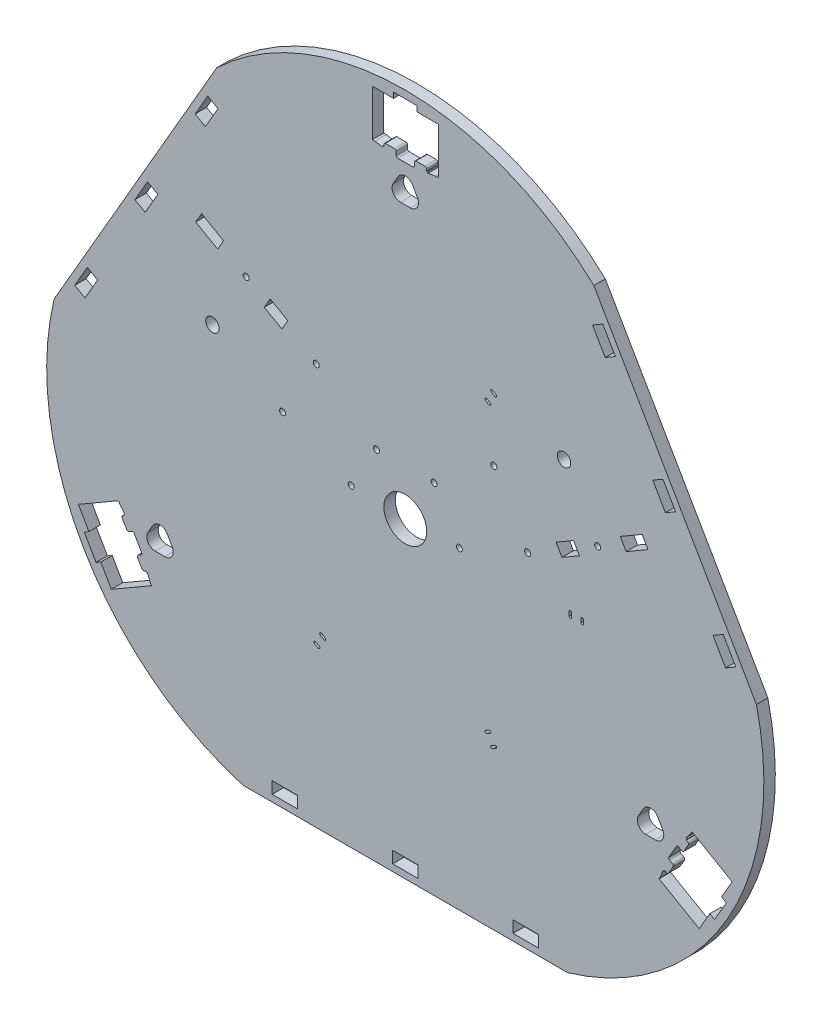
from build123d import *

# Parameters (mm, degrees)
SKETCH1_R                = 12.7
BOSS_EXTRUDE1_DEPTH      = 6.8
SKETCH2_W                = 15
SKETCH2_H                = 7
CUT_EXTRUDE1_DEPTH       = 6.8
CUT_EXTRUDE2_DEPTH       = 6.8
CUT_EXTRUDE3_DEPTH       = 6.8
FILLET1_R                = 1
CIRPATTERN1_COUNT        = 3
CIRPATTERN1_COPY_1_DEPTH = 6.8
CIRPATTERN1_COPY_2_DEPTH = 6.8
FILLET1_OF_CIRPATTERN1_R = 1
SKETCH5_R                = 1.775
SKETCH5_R_2              = 4
CUT_EXTRUDE4_DEPTH       = 6.8
CIRPATTERN2_COUNT        = 3
CUT_EXTRUDE5_DEPTH       = 6.8
CIRPATTERN3_COUNT        = 4
CIRPATTERN3_ANGLE        = 180


with BuildPart() as part:
    # Sketch1 → Boss-Extrude1 (new body)
    with BuildSketch(Plane.XY):
        with BuildLine():
            Line((-96.50625, -185), (96.50625, -185))
            ThreePointArc((96.50625, -185), (191.056759621, -110.306671598), (208.4678247, 8.923135876))
            Line((208.4678247, 8.923135876), (111.9615747, 176.076864124))
            ThreePointArc((111.9615747, 176.076864124), (0, 220.613343196), (-111.9615747, 176.076864124))
            Line((-111.9615747, 176.076864124), (-208.4678247, 8.923135876))
            ThreePointArc((-208.4678247, 8.923135876), (-191.056759621, -110.306671598), (-96.50625, -185))
        make_face()
        Circle(SKETCH1_R, mode=Mode.SUBTRACT)
    extrude(amount=BOSS_EXTRUDE1_DEPTH)

    # Sketch2 → Cut-Extrude1 (cut)
    with BuildSketch(Plane.XY.offset(6.8)):
        with Locations((-71.5, -177.5)):
            Rectangle(SKETCH2_W, SKETCH2_H)
        with Locations((0, -177.5)):
            Rectangle(SKETCH2_W, SKETCH2_H)
        with Locations((71.5, -177.5)):
            Rectangle(SKETCH2_W, SKETCH2_H)
    cut_extrude1 = extrude(amount=-CUT_EXTRUDE1_DEPTH, mode=Mode.SUBTRACT)

    # Sketch3 → Cut-Extrude2 (cut)
    with BuildSketch(Plane.XY.offset(6.8)):
        Polygon((0, 216.05), (7, 216.05), (7, 212.8), (19.58, 212.8), (19.58, 185.3), (18.08, 185.3), (13.535999488, 184.600010636), (13.270052338, 185.3), (12.7, 185.3), (12.7, 187.3), (5.45, 187.3), (5.45, 183.3), (0, 183.3), align=None)
    cut_extrude2 = extrude(amount=-CUT_EXTRUDE2_DEPTH, mode=Mode.SUBTRACT)

    # Mirror1: Cut-Extrude2 across plane
    add(cut_extrude2.mirror(Plane(origin=(0, 0, 0), x_dir=(0, 0, 1), z_dir=(1, 0, 0))), mode=Mode.SUBTRACT)

    # Sketch4 → Cut-Extrude3 (cut)
    with BuildSketch(Plane.XY.offset(6.8)):
        with BuildLine():
            Line((-2.9, 161.527052658), (2.9, 161.527052658))
            ThreePointArc((2.9, 161.527052658), (7.186825749, 164.002052658), (7.186825749, 168.952052658))
            Line((7.186825749, 168.952052658), (4.286825749, 173.975))
            ThreePointArc((4.286825749, 173.975), (0, 176.45), (-4.286825749, 173.975))
            Line((-4.286825749, 173.975), (-7.186825749, 168.952052658))
            ThreePointArc((-7.186825749, 168.952052658), (-7.186825749, 164.002052658), (-2.9, 161.527052658))
        make_face()
    cut_extrude3 = extrude(amount=-CUT_EXTRUDE3_DEPTH, mode=Mode.SUBTRACT)

    # Fillet1
    fillet1_edges = [part.edges().sort_by_distance(p)[0] for p in [
        (-5.45, 183.3, 3.4),
        (-5.45, 187.3, 3.4),
        (-12.7, 187.3, 3.4),
        (12.7, 187.3, 3.4),
        (5.45, 187.3, 3.4),
        (5.45, 183.3, 3.4),
    ]]
    fillet(fillet1_edges, radius=FILLET1_R)

    # CirPattern1: Cut-Extrude2, Cut-Extrude3, Cut-Extrude1 ×3 about axis
    cirpattern1_axis = Axis((0, 0, 0), (0, 0, 1))
    for i in range(1, CIRPATTERN1_COUNT):
        add(cut_extrude2.rotate(cirpattern1_axis, i * 360 / CIRPATTERN1_COUNT), mode=Mode.SUBTRACT)
        add(cut_extrude3.rotate(cirpattern1_axis, i * 360 / CIRPATTERN1_COUNT), mode=Mode.SUBTRACT)
        add(cut_extrude1.rotate(cirpattern1_axis, i * 360 / CIRPATTERN1_COUNT), mode=Mode.SUBTRACT)

    # CirPattern1 copy 1 sketch → CirPattern1 copy 1 (cut)
    with BuildSketch(Plane(origin=(0, 0, 6.8), x_dir=(0.5, -0.866025404, 0), z_dir=(0, 0, 1))):
        Polygon((0, -216.05), (7, -216.05), (7, -212.8), (19.58, -212.8), (19.58, -185.3), (18.08, -185.3), (13.535999488, -184.600010636), (13.270052338, -185.3), (12.7, -185.3), (12.7, -187.3), (5.45, -187.3), (5.45, -183.3), (0, -183.3), align=None)
    extrude(amount=-CIRPATTERN1_COPY_1_DEPTH, mode=Mode.SUBTRACT)

    # CirPattern1 copy 2 sketch → CirPattern1 copy 2 (cut)
    with BuildSketch(Plane(origin=(0, 0, 6.8), x_dir=(0.5, 0.866025404, 0), z_dir=(0, 0, 1))):
        Polygon((0, -216.05), (7, -216.05), (7, -212.8), (19.58, -212.8), (19.58, -185.3), (18.08, -185.3), (13.535999488, -184.600010636), (13.270052338, -185.3), (12.7, -185.3), (12.7, -187.3), (5.45, -187.3), (5.45, -183.3), (0, -183.3), align=None)
    extrude(amount=-CIRPATTERN1_COPY_2_DEPTH, mode=Mode.SUBTRACT)

    # Fillet1 of CirPattern1
    fillet1_of_cirpattern1_edges = [part.edges().sort_by_distance(p)[0] for p in [
        (-156.017456514, -96.369838451, 3.4),
        (-159.481558129, -98.369838451, 3.4),
        (-155.856558129, -104.648522628, 3.4),
        (-168.556558129, -82.651477372, 3.4),
        (-164.931558129, -88.930161549, 3.4),
        (-161.467456514, -86.930161549, 3.4),
        (161.467456514, -86.930161549, 3.4),
        (164.931558129, -88.930161549, 3.4),
        (168.556558129, -82.651477372, 3.4),
        (155.856558129, -104.648522628, 3.4),
        (159.481558129, -98.369838451, 3.4),
        (156.017456514, -96.369838451, 3.4),
    ]]
    fillet(fillet1_of_cirpattern1_edges, radius=FILLET1_OF_CIRPATTERN1_R)

    # Sketch5 → Cut-Extrude4 (cut)
    with BuildSketch(Plane.XY.offset(6.8)):
        with Locations((-94.481061156, 77.354001725)):
            Circle(SKETCH5_R)
        with Locations((-52.85988025, 53.324001725)):
            Circle(SKETCH5_R)
        with Locations((-114.481061156, 42.712985573)):
            Circle(SKETCH5_R_2)
        with Locations((-72.85988025, 18.682985573)):
            Circle(SKETCH5_R)
        with Locations((-17.113134796, 27.200781057)):
            Circle(SKETCH5_R)
        with Locations((-32.113134796, 1.220018943)):
            Circle(SKETCH5_R)
        Polygon((-124.376886779, 90.572912811), (-111.386505722, 83.072912811), (-107.886505722, 89.135090638), (-120.876886779, 96.635090638), align=None)
        Polygon((-80.173692801, 73.135090638), (-69.781387956, 67.135090638), (-73.281387956, 61.072912811), (-83.673692801, 67.072912811), align=None)
    cut_extrude4 = extrude(amount=-CUT_EXTRUDE4_DEPTH, mode=Mode.SUBTRACT)

    # CirPattern2: Cut-Extrude4 ×3 about axis, 1 skipped
    cirpattern2_axis = Axis((0, 0, 6.8), (0, 0, 1))
    add([cut_extrude4.rotate(cirpattern2_axis, i * 360 / CIRPATTERN2_COUNT) for i in range(1, CIRPATTERN2_COUNT) if i not in (1,)], mode=Mode.SUBTRACT)

    # Sketch6 → Cut-Extrude5 (cut)
    with BuildSketch(Plane.XY.offset(6.8)):
        with BuildLine():
            Line((49.664230485, 83.620970518), (47.585769515, 84.820970518))
            ThreePointArc((47.585769515, 84.820970518), (47.311250463, 85.845489571), (48.335769515, 86.120008624))
            Line((48.335769515, 86.120008624), (50.414230485, 84.920008624))
            ThreePointArc((50.414230485, 84.920008624), (50.688749537, 83.895489571), (49.664230485, 83.620970518))
        make_face()
        with BuildLine():
            Line((53.164230485, 89.683148345), (51.085769515, 90.883148345))
            ThreePointArc((51.085769515, 90.883148345), (50.811250463, 91.907667397), (51.835769515, 92.18218645))
            Line((51.835769515, 92.18218645), (53.914230485, 90.98218645))
            ThreePointArc((53.914230485, 90.98218645), (54.188749537, 89.957667397), (53.164230485, 89.683148345))
        make_face()
    cut_extrude5 = extrude(amount=-CUT_EXTRUDE5_DEPTH, mode=Mode.SUBTRACT)

    # CirPattern3: Cut-Extrude5 ×4 about axis
    cirpattern3_axis = Axis((0, 0, 0), (0, 0, -1))
    for i in range(1, CIRPATTERN3_COUNT):
        add(cut_extrude5.rotate(cirpattern3_axis, i * CIRPATTERN3_ANGLE / (CIRPATTERN3_COUNT - 1)), mode=Mode.SUBTRACT)


solid = part.part
